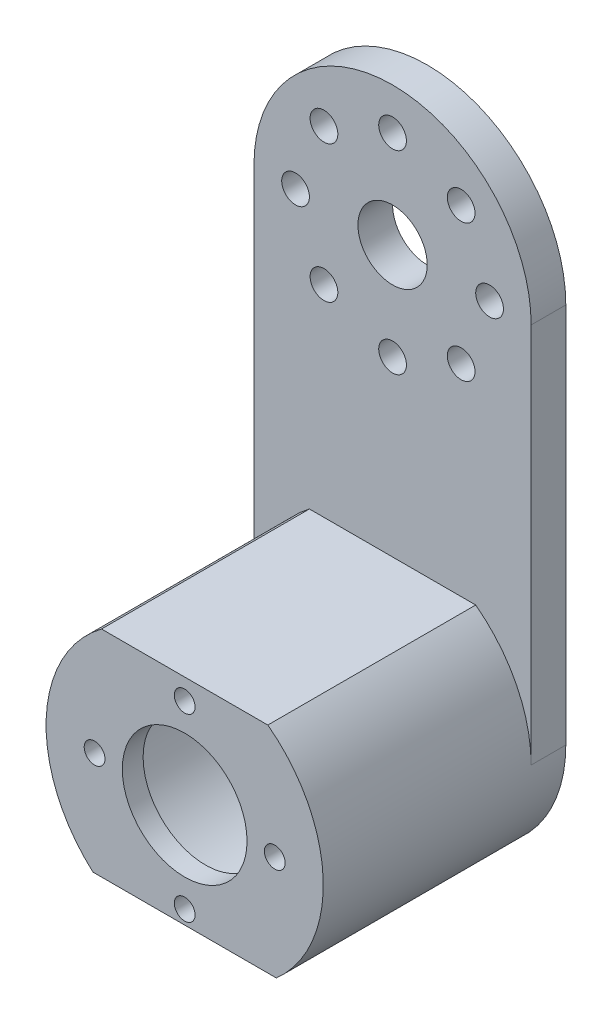
from build123d import *
from build123d.topology import SkipClean

# Parameters (mm, degrees)
ESQUISSE1_R           = 15
ESQUISSE1_R_2         = 5
ESQUISSE1_R_3         = 2
EXTRUSION1_DEPTH      = 5
ESQUISSE2_R           = 9
ESQUISSE2_R_2         = 1.5
EXTRUSION2_DEPTH      = 30
ESQUISSE3_R           = 15
EXTRUSION3_DEPTH      = 27
EXTRUSION4_DEPTH      = 104.198837203
EXTRUSION4_DEPTH_BACK = 104.198837203


with BuildPart() as part:
    # Esquisse1 → Extrusion1 (new body)
    with BuildSketch(Plane.XY):
        with BuildLine():
            Line((20, -20), (20, -75))
            ThreePointArc((20, -75), (0, -95), (-20, -75))
            Line((-20, -75), (-20, -20))
            ThreePointArc((-20, -20), (0, 0), (20, -20))
        make_face()
        with Locations((0, -75)):
            Circle(ESQUISSE1_R, mode=Mode.SUBTRACT)
        with Locations((0, -20)):
            Circle(ESQUISSE1_R_2, mode=Mode.SUBTRACT)
        with Locations((-14, -20)):
            Circle(ESQUISSE1_R_3, mode=Mode.SUBTRACT)
        with Locations((-9.899494937, -10.100505063)):
            Circle(ESQUISSE1_R_3, mode=Mode.SUBTRACT)
        with Locations((0, -6)):
            Circle(ESQUISSE1_R_3, mode=Mode.SUBTRACT)
        with Locations((9.899494937, -10.100505063)):
            Circle(ESQUISSE1_R_3, mode=Mode.SUBTRACT)
        with Locations((14, -20)):
            Circle(ESQUISSE1_R_3, mode=Mode.SUBTRACT)
        with Locations((9.899494937, -29.899494937)):
            Circle(ESQUISSE1_R_3, mode=Mode.SUBTRACT)
        with Locations((0, -34)):
            Circle(ESQUISSE1_R_3, mode=Mode.SUBTRACT)
        with Locations((-9.899494937, -29.899494937)):
            Circle(ESQUISSE1_R_3, mode=Mode.SUBTRACT)
    extrude(amount=EXTRUSION1_DEPTH)

    # Esquisse2 → Extrusion2 (add)
    with SkipClean():  # the faces are left unmerged after this step: merging them gives an invalid solid
        with BuildSketch(Plane.XY.offset(5)):
            with BuildLine():
                Line((12, -59), (-12, -59))
                ThreePointArc((-12, -59), (0, -95), (12, -59))
            make_face()
            with Locations((0, -75)):
                Circle(ESQUISSE2_R, mode=Mode.SUBTRACT)
            with Locations((0, -62)):
                Circle(ESQUISSE2_R_2, mode=Mode.SUBTRACT)
            with Locations((0, -88)):
                Circle(ESQUISSE2_R_2, mode=Mode.SUBTRACT)
            with Locations((-13, -75)):
                Circle(ESQUISSE2_R_2, mode=Mode.SUBTRACT)
            with Locations((13, -75)):
                Circle(ESQUISSE2_R_2, mode=Mode.SUBTRACT)
        extrude(amount=EXTRUSION2_DEPTH)

    # Esquisse3 → Extrusion3 (cut)
    with SkipClean():  # the faces are left unmerged after this step: merging them gives an invalid solid
        with BuildSketch(Plane(origin=(0, 0, 5), x_dir=(-1, 0, 0), z_dir=(0, 0, -1))):
            with Locations((0, -75)):
                Circle(ESQUISSE3_R)
        extrude(amount=-EXTRUSION3_DEPTH, mode=Mode.SUBTRACT)

    # Esquisse4 → Extrusion4 (cut, two sides: drawn at the far end of the back side and taken through both)
    with SkipClean():  # the faces are left unmerged after this step: merging them gives an invalid solid
        with BuildSketch(Plane(origin=(0, 0, 0), x_dir=(0, 0, -1), z_dir=(1, 0, 0)).offset(-EXTRUSION4_DEPTH_BACK)):
            Polygon((-35, -95), (-30, -95), (-35, -90), align=None)
        extrude(amount=EXTRUSION4_DEPTH + EXTRUSION4_DEPTH_BACK, mode=Mode.SUBTRACT)


solid = part.part
